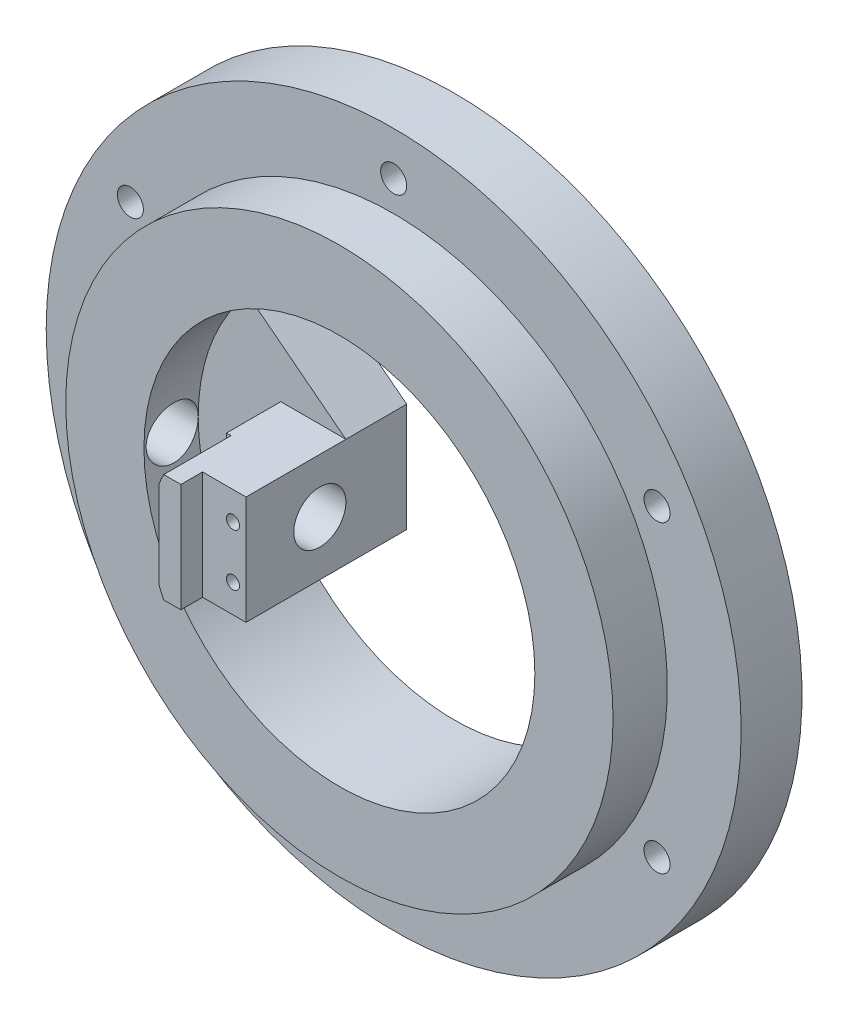
from build123d import *

# Parameters (mm, degrees)
SKETCH1_R            = 70
SKETCH1_R_2          = 45
BOSS_EXTRUDE1_DEPTH  = 4
SKETCH3_R            = 60
SKETCH3_R_2          = 45
BOSS_EXTRUDE4_DEPTH  = 32
SKETCH6_W            = 16
SKETCH6_H            = 10
SKETCH6_W_2          = 34
BOSS_EXTRUDE5_DEPTH  = 12.5
SKETCH10_W           = 15
SKETCH10_H           = 22
BOSS_EXTRUDE6_DEPTH  = 12.5
SKETCH11_W           = 34
SKETCH11_H           = 4
BOSS_EXTRUDE7_DEPTH  = 30
SKETCH12_W           = 17.229041164
SKETCH12_H           = 10
CUT_EXTRUDE3_DEPTH   = 12.5
CUT_EXTRUDE4_DEPTH   = 12.5
CUT_EXTRUDE5_DEPTH   = 12.5
SKETCH20_W           = 10
SKETCH20_H           = 25
CUT_EXTRUDE11_DEPTH  = 4
SKETCH21_R           = 45
SKETCH21_R_2         = 32.5
BOSS_EXTRUDE8_DEPTH  = 15
SKETCH22_W           = 17.163263372
SKETCH22_H           = 25
CUT_EXTRUDE12_DEPTH  = 5
SKETCH25_R           = 63
SKETCH25_R_2         = 60
BOSS_EXTRUDE9_DEPTH  = 50
SKETCH26_R           = 80
SKETCH26_R_2         = 70
BOSS_EXTRUDE10_DEPTH = 4
SKETCH29_R           = 3
CUT_EXTRUDE14_DEPTH  = 5
SKETCH30_R           = 80
SKETCH30_R_2         = 3
BOSS_EXTRUDE11_DEPTH = 10
SKETCH16_R           = 6
CUT_EXTRUDE10_DEPTH  = 100
SKETCH31_W           = 42
SKETCH31_H           = 25
CUT_EXTRUDE15_DEPTH  = 1
SKETCH33_R           = 81.797304038
SKETCH33_R_2         = 27.899813831
CUT_EXTRUDE17_DEPTH  = 37.5
SKETCH34_R           = 1.5
CUT_EXTRUDE18_DEPTH  = 10


with BuildPart() as part:
    # Sketch1 → Boss-Extrude1 (new body)
    with BuildSketch(Plane.XY):
        Circle(SKETCH1_R)
        Circle(SKETCH1_R_2, mode=Mode.SUBTRACT)
    extrude(amount=BOSS_EXTRUDE1_DEPTH)

    # Sketch3 → Boss-Extrude4 (add)
    with BuildSketch(Plane.XY):
        Circle(SKETCH3_R)
        Circle(SKETCH3_R_2, mode=Mode.SUBTRACT)
    extrude(amount=BOSS_EXTRUDE4_DEPTH)

    # Sketch6 → Boss-Extrude5 (add, symmetric)
    with BuildSketch(Plane(origin=(0, 0, 0), x_dir=(1, 0, 0), z_dir=(0, 1, 0))):
        with Locations((37, -27)):
            Rectangle(SKETCH6_W, SKETCH6_H)
        with Locations((-28, -27)):
            Rectangle(SKETCH6_W_2, SKETCH6_H)
    extrude(amount=BOSS_EXTRUDE5_DEPTH, both=True)

    # Sketch10 → Boss-Extrude6 (add, symmetric)
    with BuildSketch(Plane(origin=(0, 0, 0), x_dir=(1, 0, 0), z_dir=(0, 1, 0))):
        with Locations((-18.5, -11)):
            Rectangle(SKETCH10_W, SKETCH10_H)
    extrude(amount=BOSS_EXTRUDE6_DEPTH, both=True)

    # Sketch11 → Boss-Extrude7 (add, symmetric)
    with BuildSketch(Plane(origin=(0, 0, 0), x_dir=(1, 0, 0), z_dir=(0, 1, 0))):
        with Locations((-28, -2)):
            Rectangle(SKETCH11_W, SKETCH11_H)
    extrude(amount=BOSS_EXTRUDE7_DEPTH, both=True)

    # Sketch12 → Cut-Extrude3 (cut, symmetric)
    with BuildSketch(Plane(origin=(0, 0, 0), x_dir=(1, 0, 0), z_dir=(0, 1, 0))):
        with Locations((-34.614520582, -27)):
            Rectangle(SKETCH12_W, SKETCH12_H)
    extrude(amount=CUT_EXTRUDE3_DEPTH, both=True, mode=Mode.SUBTRACT)

    # Sketch13 → Cut-Extrude4 (cut, symmetric)
    with BuildSketch(Plane.XY):
        Polygon((-33.541019662, 30), (-11, 12.5), (-11, 30), align=None)
    extrude(amount=CUT_EXTRUDE4_DEPTH, both=True, mode=Mode.SUBTRACT)

    # Sketch14 → Cut-Extrude5 (cut, symmetric)
    with BuildSketch(Plane.XY):
        Polygon((-33.541019662, -30), (-11, -12.5), (-11, -30), align=None)
    extrude(amount=CUT_EXTRUDE5_DEPTH, both=True, mode=Mode.SUBTRACT)

    # Sketch20 → Cut-Extrude11 (cut)
    with BuildSketch(Plane.XY.offset(32)):
        with Locations((-16, 0)):
            Rectangle(SKETCH20_W, SKETCH20_H)
        with Locations((34, 0)):
            Rectangle(SKETCH20_W, SKETCH20_H)
    extrude(amount=-CUT_EXTRUDE11_DEPTH, mode=Mode.SUBTRACT)

    # Sketch21 → Boss-Extrude8 (add)
    with BuildSketch(Plane.XY.offset(32)):
        Circle(SKETCH21_R)
        Circle(SKETCH21_R_2, mode=Mode.SUBTRACT)
    extrude(amount=-BOSS_EXTRUDE8_DEPTH)

    # Sketch22 → Cut-Extrude12 (cut)
    with BuildSketch(Plane.XY.offset(32)):
        with Locations((34.647409478, 0)):
            Rectangle(SKETCH22_W, SKETCH22_H)
    extrude(amount=-CUT_EXTRUDE12_DEPTH, mode=Mode.SUBTRACT)

    # Sketch25 → Boss-Extrude9 (add)
    with BuildSketch(Plane.XY.offset(4)):
        Circle(SKETCH25_R)
        Circle(SKETCH25_R_2, mode=Mode.SUBTRACT)
    extrude(amount=BOSS_EXTRUDE9_DEPTH)

    # Sketch26 → Boss-Extrude10 (add)
    with BuildSketch(Plane(origin=(0, 0, 0), x_dir=(-1, 0, 0), z_dir=(0, 0, -1))):
        Circle(SKETCH26_R)
        Circle(SKETCH26_R_2, mode=Mode.SUBTRACT)
    extrude(amount=-BOSS_EXTRUDE10_DEPTH)

    # Sketch29 → Cut-Extrude14 (cut)
    with BuildSketch(Plane.XY.offset(4)):
        with Locations((0, 70)):
            Circle(SKETCH29_R)
        with Locations((60.621778265, 35)):
            Circle(SKETCH29_R)
        with Locations((60.621778265, -35)):
            Circle(SKETCH29_R)
        with Locations((0, -70)):
            Circle(SKETCH29_R)
        with Locations((-60.621778265, -35)):
            Circle(SKETCH29_R)
        with Locations((-60.621778265, 35)):
            Circle(SKETCH29_R)
    extrude(amount=-CUT_EXTRUDE14_DEPTH, mode=Mode.SUBTRACT)

    # Sketch30 → Boss-Extrude11 (add)
    with BuildSketch(Plane(origin=(0, 0, 0), x_dir=(-1, 0, 0), z_dir=(0, 0, -1))):
        Circle(SKETCH30_R)
        with Locations((-60.621778265, 35)):
            Circle(SKETCH30_R_2, mode=Mode.SUBTRACT)
        with Locations((-60.621778265, -35)):
            Circle(SKETCH30_R_2, mode=Mode.SUBTRACT)
        with Locations((0, -70)):
            Circle(SKETCH30_R_2, mode=Mode.SUBTRACT)
        with Locations((60.621778265, -35)):
            Circle(SKETCH30_R_2, mode=Mode.SUBTRACT)
        with Locations((60.621778265, 35)):
            Circle(SKETCH30_R_2, mode=Mode.SUBTRACT)
        with Locations((0, 70)):
            Circle(SKETCH30_R_2, mode=Mode.SUBTRACT)
        with BuildLine():
            Line((11, -12.5), (33.541019662, -30))
            ThreePointArc((33.541019662, -30), (-45, 0), (33.541019662, 30))
            Line((33.541019662, 30), (11, 12.5))
            Line((11, 12.5), (11, -12.5))
        make_face(mode=Mode.SUBTRACT)
    extrude(amount=BOSS_EXTRUDE11_DEPTH)

    # Sketch16 → Cut-Extrude10 (cut)
    with BuildSketch(Plane(origin=(-11, 0, 0), x_dir=(0, 0, -1), z_dir=(1, 0, 0))):
        with Locations((-10, 0)):
            Circle(SKETCH16_R)
    extrude(amount=-CUT_EXTRUDE10_DEPTH, mode=Mode.SUBTRACT)

    # Sketch31 → Cut-Extrude15 (cut)
    with BuildSketch(Plane.XY.offset(28)):
        Rectangle(SKETCH31_W, SKETCH31_H)
    extrude(amount=-CUT_EXTRUDE15_DEPTH, mode=Mode.SUBTRACT)

    # Sketch33 → Cut-Extrude17 (cut)
    with BuildSketch(Plane.XY.offset(54)):
        Circle(SKETCH33_R)
        Circle(SKETCH33_R_2, mode=Mode.SUBTRACT)
    extrude(amount=-CUT_EXTRUDE17_DEPTH, mode=Mode.SUBTRACT)

    # Sketch34 → Cut-Extrude18 (cut)
    with BuildSketch(Plane.XY.offset(27)):
        with Locations((-14, 6)):
            Circle(SKETCH34_R)
        with Locations((-14, -6)):
            Circle(SKETCH34_R)
    extrude(amount=-CUT_EXTRUDE18_DEPTH, mode=Mode.SUBTRACT)


solid = part.part
